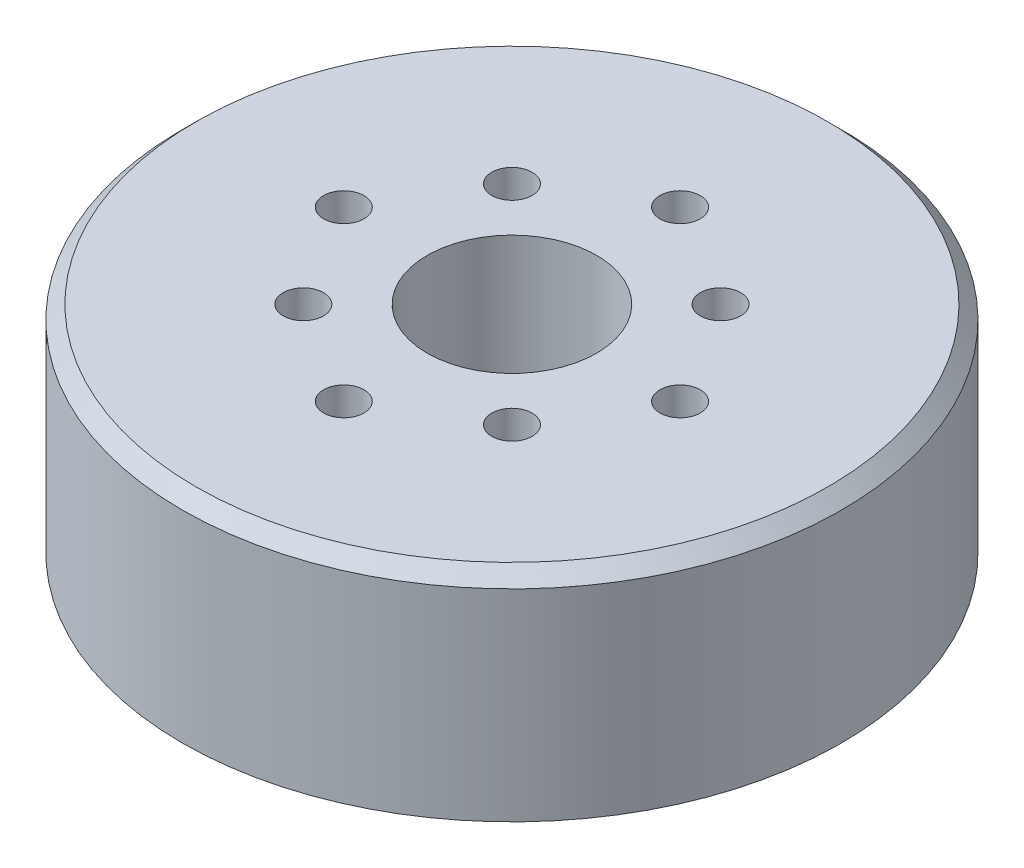
from build123d import *

# Parameters (mm, degrees)
ESQUISSE1_R        = 24.5
ESQUISSE1_R_2      = 1.5
ESQUISSE1_R_3      = 6.3
BOSS_EXTRU_1_DEPTH = 16
CHANFREIN1_SIZE    = 1


with BuildPart() as part:
    # Esquisse1 → Boss.-Extru.1 (new body)
    with BuildSketch(Plane(origin=(0, 0, 0), x_dir=(1, 0, 0), z_dir=(0, 1, 0))):
        Circle(ESQUISSE1_R)
        with Locations((0, 12.5)):
            Circle(ESQUISSE1_R_2, mode=Mode.SUBTRACT)
        with Locations((12.5, 0)):
            Circle(ESQUISSE1_R_2, mode=Mode.SUBTRACT)
        with Locations((0, -12.5)):
            Circle(ESQUISSE1_R_2, mode=Mode.SUBTRACT)
        with Locations((-12.5, 0)):
            Circle(ESQUISSE1_R_2, mode=Mode.SUBTRACT)
        with Locations((7.753017526, 7.753017526)):
            Circle(ESQUISSE1_R_2, mode=Mode.SUBTRACT)
        with Locations((7.753017526, -7.753017526)):
            Circle(ESQUISSE1_R_2, mode=Mode.SUBTRACT)
        with Locations((-7.753017526, -7.753017526)):
            Circle(ESQUISSE1_R_2, mode=Mode.SUBTRACT)
        with Locations((-7.753017526, 7.753017526)):
            Circle(ESQUISSE1_R_2, mode=Mode.SUBTRACT)
        Circle(ESQUISSE1_R_3, mode=Mode.SUBTRACT)
    extrude(amount=BOSS_EXTRU_1_DEPTH)

    # Chanfrein1
    chanfrein1_edges = [part.edges().sort_by_distance(p)[0] for p in [
        (-24.5, 16, 0),
    ]]
    chamfer(chanfrein1_edges, length=CHANFREIN1_SIZE)


solid = part.part
